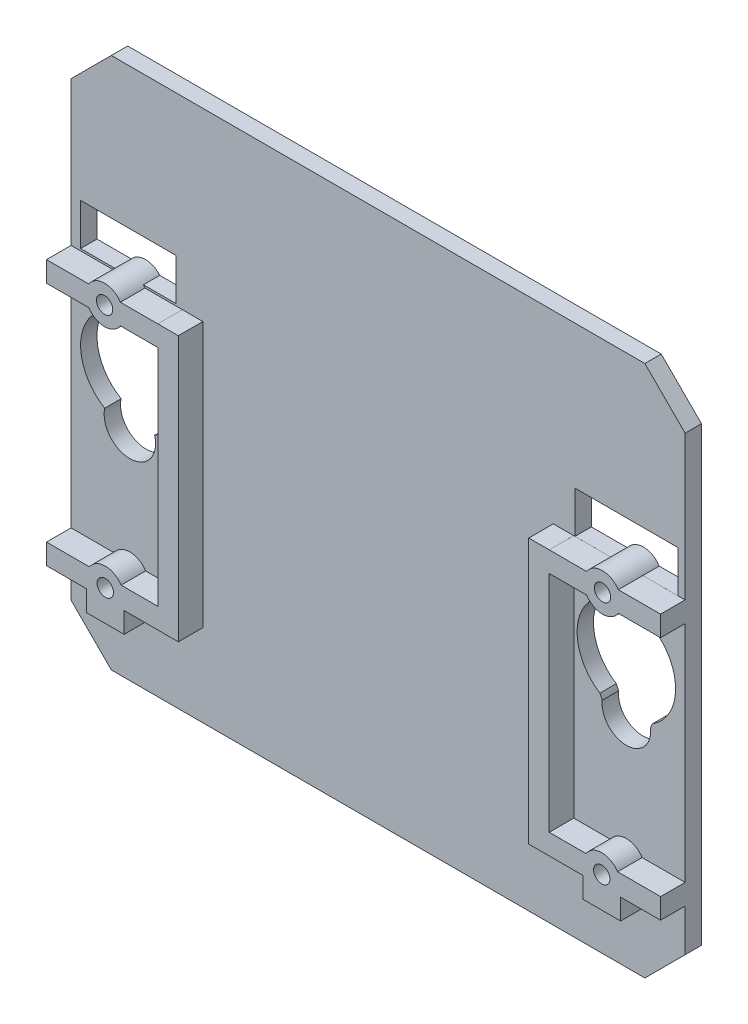
from build123d import *

# Parameters (mm, degrees)
BOSS_EXTRUDE3_DEPTH = 2
SKETCH7_R           = 1
SKETCH7_W           = 2.5
SKETCH7_H           = 2.5
BOSS_EXTRUDE5_DEPTH = 3
SKETCH15_R          = 6.016109345
SKETCH15_R_2        = 2.966709341
CUT_EXTRUDE5_DEPTH  = 3
CUT_EXTRUDE6_DEPTH  = 3
CUT_EXTRUDE7_DEPTH  = 10
SKETCH30_W          = 2
SKETCH30_H          = 65
BOSS_EXTRUDE6_DEPTH = 5
SKETCH31_R          = 3.139995771
SKETCH31_R_2        = 5.842822915
CUT_EXTRUDE8_DEPTH  = 5
SKETCH33_W          = 2.81704287
SKETCH33_H          = 5.093792668
CUT_EXTRUDE9_DEPTH  = 5


with BuildPart() as part:
    # Sketch2 → Boss-Extrude3 (new body)
    with BuildSketch(Plane.XY):
        Polygon((62.078732257, 67), (7.070378023, 67), (2.153513577, 62.087886246), (2.153513577, 6.916864445), (7.070378023, 2), (62.078732257, 2), (67.153513577, 7.083274694), (67.153513577, 61.921636784), align=None)
        with BuildLine():
            ThreePointArc((12.561398281, 29.386897281), (12.405099811, 29.087669445), (12.28230409, 28.773205265))
            ThreePointArc((12.28230409, 28.773205265), (9.332354964, 25.48092154), (6.384978263, 28.775508397))
            ThreePointArc((6.384978263, 28.775508397), (6.272687262, 29.080787813), (6.128559615, 29.372390302))
            ThreePointArc((6.128559615, 29.372390302), (9.319946418, 40.479834047), (12.561398281, 29.386897281))
        make_face(mode=Mode.SUBTRACT)
        with BuildLine():
            Line((7.315683042, 44.45), (3.053513577, 44.45))
            Line((3.053513577, 44.45), (3.053513577, 49.55))
            Line((3.053513577, 49.55), (15.603513577, 49.55))
            Line((15.603513577, 49.55), (15.603513577, 44.45))
            Line((15.603513577, 44.45), (11.175073004, 44.45))
            ThreePointArc((11.175073004, 44.45), (9.245378023, 45.49849), (7.315683042, 44.45))
        make_face(mode=Mode.SUBTRACT)
    boss_extrude3 = extrude(amount=BOSS_EXTRUDE3_DEPTH)

    # Sketch7 → Boss-Extrude5 (add)
    with BuildSketch(Plane.XY.offset(2)):
        with BuildLine():
            Line((15.753513577, 14.57), (11.264187035, 14.57))
            ThreePointArc((11.264187035, 14.57), (9.333513577, 15.62), (7.40284012, 14.57))
            Line((7.40284012, 14.57), (2.153513577, 14.57))
            Line((2.153513577, 14.57), (2.153513577, 12.07))
            Line((2.153513577, 12.07), (7.033513577, 12.07))
            Line((7.033513577, 12.07), (7.40284012, 12.07))
            ThreePointArc((7.40284012, 12.07), (9.333513577, 11.02), (11.264187035, 12.07))
            Line((11.264187035, 12.07), (11.633513577, 12.07))
            Line((11.633513577, 12.07), (15.753513577, 12.07))
            Line((15.753513577, 12.07), (15.753513577, 14.57))
        make_face()
        with Locations((9.333513577, 13.32)):
            Circle(SKETCH7_R, mode=Mode.SUBTRACT)
        with BuildLine():
            Line((11.633513577, 9.547776159), (11.633513577, 12.07))
            Line((11.633513577, 12.07), (11.264187035, 12.07))
            ThreePointArc((11.264187035, 12.07), (9.333513577, 11.02), (7.40284012, 12.07))
            Line((7.40284012, 12.07), (7.033513577, 12.07))
            Line((7.033513577, 12.07), (7.033513577, 9.547776159))
            Line((7.033513577, 9.547776159), (11.633513577, 9.547776159))
        make_face()
        with Locations((17.003513577, 13.32)):
            Rectangle(SKETCH7_W, SKETCH7_H)
        with BuildLine():
            Line((15.753513577, 16.534568208), (15.753513577, 14.57))
            Line((15.753513577, 14.57), (18.253513577, 14.57))
            Line((18.253513577, 14.57), (18.253513577, 16.534568208))
            Line((18.253513577, 16.534568208), (18.253513577, 44.45))
            Line((18.253513577, 44.45), (15.753513577, 44.45))
            Line((15.753513577, 44.45), (15.753513577, 44.44849))
            Line((15.753513577, 44.44849), (11.17605148, 44.44849))
            ThreePointArc((11.17605148, 44.44849), (11.17556239, 44.449245096), (11.175073004, 44.45))
            ThreePointArc((11.175073004, 44.45), (10.343450652, 45.219439406), (9.245378023, 45.49849))
            ThreePointArc((9.245378023, 45.49849), (8.147305393, 45.219439406), (7.315683042, 44.45))
            ThreePointArc((7.315683042, 44.45), (7.315193656, 44.449245096), (7.314704565, 44.44849))
            Line((7.314704565, 44.44849), (2.153513577, 44.44849))
            Line((2.153513577, 44.44849), (2.153513577, 41.94849))
            Line((2.153513577, 41.94849), (7.314704565, 41.94849))
            ThreePointArc((7.314704565, 41.94849), (9.245378023, 40.89849), (11.17605148, 41.94849))
            Line((11.17605148, 41.94849), (15.753513577, 41.94849))
            Line((15.753513577, 41.94849), (15.753513577, 16.534568208))
        make_face()
        with Locations((9.245378023, 43.19849)):
            Circle(SKETCH7_R, mode=Mode.SUBTRACT)
    boss_extrude5 = extrude(amount=BOSS_EXTRUDE5_DEPTH)

    # Mirror4: Boss-Extrude3, Boss-Extrude5 across plane
    add(boss_extrude3.mirror(Plane.ZY.offset(-34.653513577)))
    add(boss_extrude5.mirror(Plane.ZY.offset(-34.653513577)))

    # Sketch15 → Cut-Extrude5 (cut)
    with BuildSketch(Plane.XY.offset(2)):
        with Locations((9.333513577, 34.46374)):
            Circle(SKETCH15_R)
        with Locations((9.333513577, 28.447630655)):
            Circle(SKETCH15_R_2)
    cut_extrude5 = extrude(amount=-CUT_EXTRUDE5_DEPTH, mode=Mode.SUBTRACT)

    # Sketch21 → Cut-Extrude6 (cut)
    with BuildSketch(Plane.XY.offset(2)):
        with BuildLine():
            Line((3.317404233, 44.701735967), (7.504616246, 44.701735967))
            ThreePointArc((7.504616246, 44.701735967), (9.245378023, 45.49849), (10.986139799, 44.701735967))
            Line((10.986139799, 44.701735967), (15.349622922, 44.701735967))
            Line((15.349622922, 44.701735967), (15.349622922, 49.701735967))
            Line((15.349622922, 49.701735967), (3.317404233, 49.701735967))
            Line((3.317404233, 49.701735967), (3.317404233, 44.701735967))
        make_face()
    extrude(amount=-CUT_EXTRUDE6_DEPTH, mode=Mode.SUBTRACT)

    # Sketch29 → Cut-Extrude7 (cut)
    with BuildSketch(Plane.XY.offset(2)):
        with BuildLine():
            Line((3.317404233, 44.795528635), (7.590244313, 44.795528635))
            ThreePointArc((7.590244313, 44.795528635), (9.245378023, 45.49849), (10.900511733, 44.795528635))
            Line((10.900511733, 44.795528635), (15.349622922, 44.795528635))
            Line((15.349622922, 44.795528635), (15.349622922, 49.795528635))
            Line((15.349622922, 49.795528635), (3.317404233, 49.795528635))
            Line((3.317404233, 49.795528635), (3.317404233, 44.795528635))
        make_face()
    cut_extrude7 = extrude(amount=-CUT_EXTRUDE7_DEPTH, mode=Mode.SUBTRACT)

    # Mirror9: Cut-Extrude7 across plane
    add(cut_extrude7.mirror(Plane.ZY.offset(-34.653513577)), mode=Mode.SUBTRACT)

    # Mirror5: Cut-Extrude5 across plane
    add(cut_extrude5.mirror(Plane.ZY.offset(-34.653513577)), mode=Mode.SUBTRACT)

    # SurfaceCut1
    split(bisect_by=Plane.ZY.offset(-34.653513577), keep=Keep.TOP)

    # Sketch30 → Boss-Extrude6 (add)
    with BuildSketch(Plane(origin=(34.653513577, 0, 0), x_dir=(0, 0, -1), z_dir=(1, 0, 0))):
        with Locations((-1, 34.5)):
            Rectangle(SKETCH30_W, SKETCH30_H)
    extrude(amount=BOSS_EXTRUDE6_DEPTH)

    # Mirror12: Boss-Extrude3, Boss-Extrude5 across plane
    add(boss_extrude3.mirror(Plane(origin=(39.653513577, 0, 0), x_dir=(0, 0, 1), z_dir=(1, 0, 0))))
    add(boss_extrude5.mirror(Plane(origin=(39.653513577, 0, 0), x_dir=(0, 0, 1), z_dir=(1, 0, 0))))

    # Sketch31 → Cut-Extrude8 (cut)
    with BuildSketch(Plane.XY.offset(2)):
        with Locations((9.333513577, 28.620917085)):
            Circle(SKETCH31_R)
        with Locations((9.333513577, 34.46374)):
            Circle(SKETCH31_R_2)
    extrude(amount=-CUT_EXTRUDE8_DEPTH, mode=Mode.SUBTRACT)

    # Sketch33 → Cut-Extrude9 (cut)
    with BuildSketch(Plane.XY.offset(2)):
        with Locations((13.562035012, 47.248632301)):
            Rectangle(SKETCH33_W, SKETCH33_H)
    extrude(amount=-CUT_EXTRUDE9_DEPTH, mode=Mode.SUBTRACT)


solid = part.part
